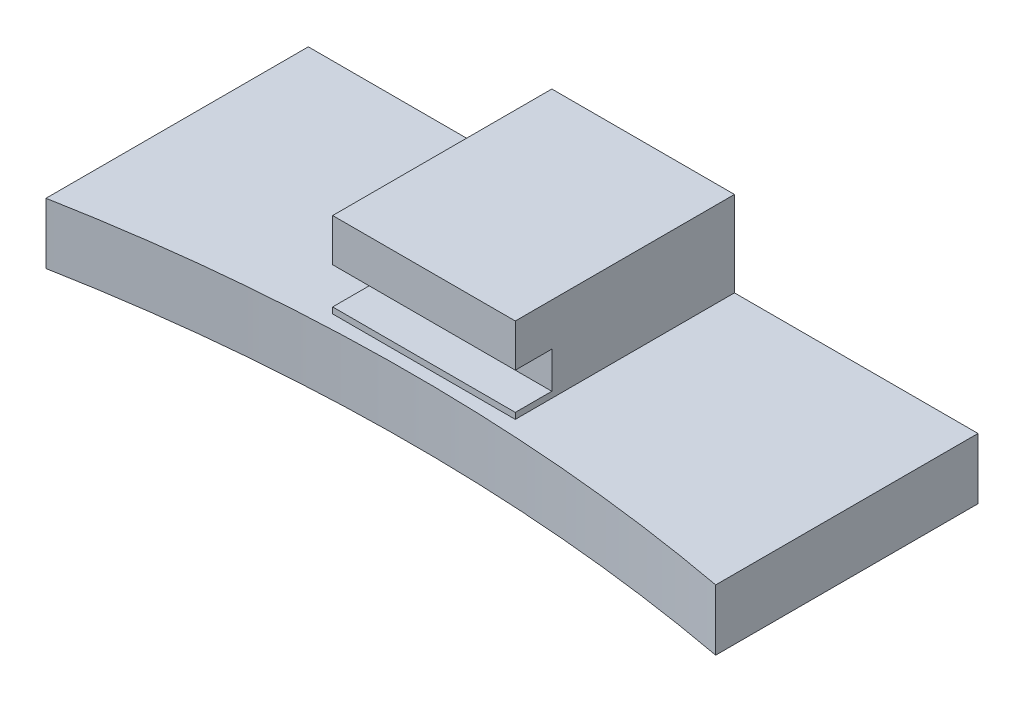
from build123d import *

# Parameters (mm, degrees)
BOSS_EXTRUDE1_DEPTH             = 5
SKETCH4_W                       = 15
SKETCH4_H                       = 18
BOSS_EXTRUDE2_DEPTH             = 0.5
SKETCH5_W                       = 15
SKETCH5_H                       = 15
BOSS_EXTRUDE3_DEPTH             = 3
SKETCH6_W                       = 15
SKETCH6_H                       = 18
BOSS_EXTRUDE4_DEPTH             = 3.5
SKETCH9_R                       = 4.5
CUT_EXTRUDE1_DEPTH              = 4
M8X1_0_TAPPED_HOLE1_D           = 7
M8X1_0_TAPPED_HOLE1_DEPTH       = 8
M8X1_0_TAPPED_HOLE1_CSINK_D     = 8.05
M8X1_0_TAPPED_HOLE1_CSINK_ANGLE = 90
M8X1_0_TAPPED_HOLE1_TIP         = 2.103012167


with BuildPart() as part:
    # Sketch1 → Boss-Extrude1 (new body)
    with BuildSketch(Plane(origin=(0, 0, 0), x_dir=(1, 0, 0), z_dir=(0, 1, 0))):
        with BuildLine():
            Line((0, 9.997621031), (0, 31.54))
            Line((0, 31.54), (55, 31.54))
            Line((55, 31.54), (55, 9.997621031))
            ThreePointArc((55, 9.997621031), (27.5, 12.54), (0, 9.997621031))
        make_face()
    extrude(amount=BOSS_EXTRUDE1_DEPTH)

    # Sketch4 → Boss-Extrude2 (add)
    with BuildSketch(Plane(origin=(0, 5, 0), x_dir=(1, 0, 0), z_dir=(0, 1, 0))):
        with Locations((27.5, 22.54)):
            Rectangle(SKETCH4_W, SKETCH4_H)
    extrude(amount=BOSS_EXTRUDE2_DEPTH)

    # Sketch5 → Boss-Extrude3 (add)
    with BuildSketch(Plane(origin=(0, 5.5, 0), x_dir=(1, 0, 0), z_dir=(0, 1, 0))):
        with Locations((27.5, 24.04)):
            Rectangle(SKETCH5_W, SKETCH5_H)
    extrude(amount=BOSS_EXTRUDE3_DEPTH)

    # Sketch6 → Boss-Extrude4 (add)
    with BuildSketch(Plane(origin=(0, 8.5, 0), x_dir=(1, 0, 0), z_dir=(0, 1, 0))):
        with Locations((27.5, 22.54)):
            Rectangle(SKETCH6_W, SKETCH6_H)
    extrude(amount=BOSS_EXTRUDE4_DEPTH)

    # Sketch9 → Cut-Extrude1 (cut)
    with BuildSketch(Plane(origin=(0, 0, -31.54), x_dir=(-1, 0, 0), z_dir=(0, 0, -1))):
        with Locations((-27.5, 6.5)):
            Circle(SKETCH9_R)
    extrude(amount=-CUT_EXTRUDE1_DEPTH, mode=Mode.SUBTRACT)

    # M8x1.0 Tapped Hole1
    with Locations(Plane(origin=(0, 0, -27.54), x_dir=(-1, 0, 0), z_dir=(0, 0, -1))):
        with Locations((-27.5, 6.5)):
            CounterSinkHole(M8X1_0_TAPPED_HOLE1_D / 2, M8X1_0_TAPPED_HOLE1_CSINK_D / 2, depth=M8X1_0_TAPPED_HOLE1_DEPTH, counter_sink_angle=M8X1_0_TAPPED_HOLE1_CSINK_ANGLE)
            with Locations((0, 0, -(M8X1_0_TAPPED_HOLE1_DEPTH + M8X1_0_TAPPED_HOLE1_TIP / 2))):  # 118° drill point
                Cone(0, M8X1_0_TAPPED_HOLE1_D / 2, M8X1_0_TAPPED_HOLE1_TIP, mode=Mode.SUBTRACT)


solid = part.part
